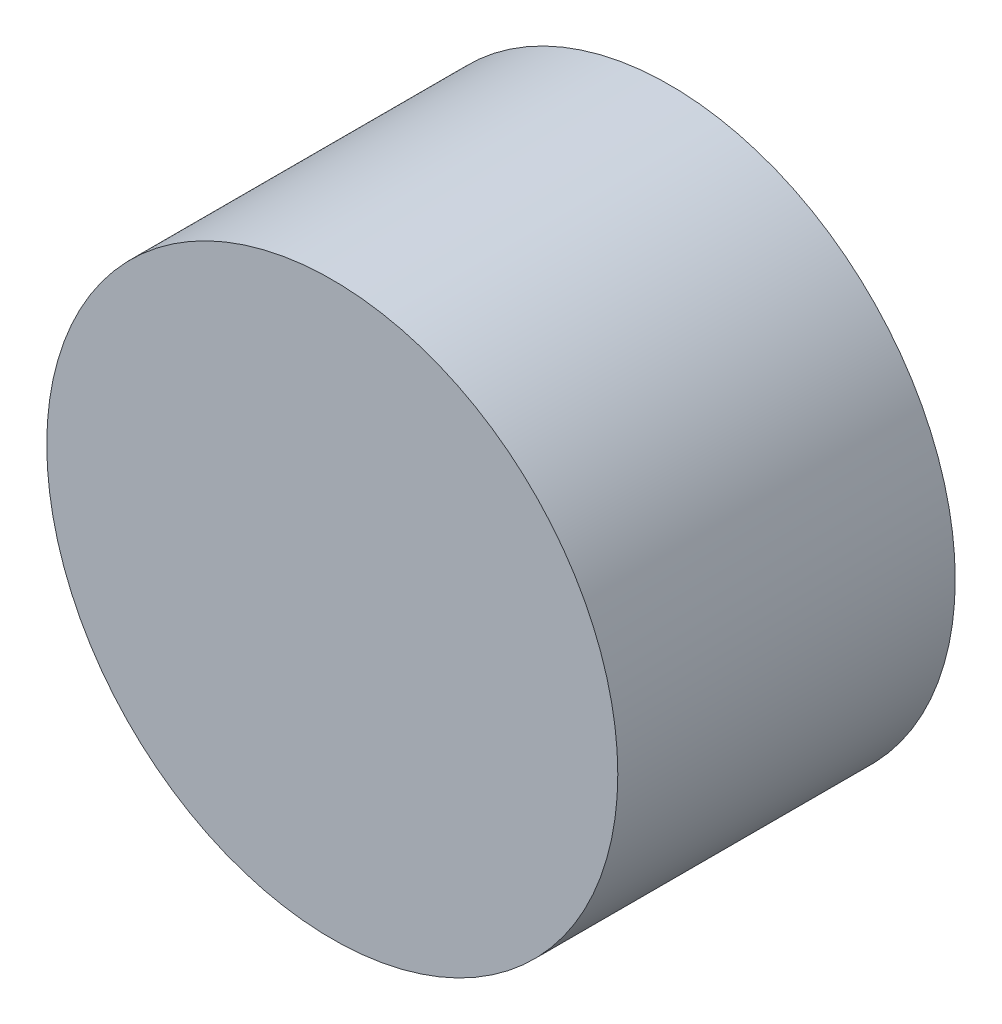
from build123d import *

# Parameters (mm, degrees)
SKETCH1_R           = 2.75
BOSS_EXTRUDE1_DEPTH = 3.25


with BuildPart() as part:
    # Sketch1 → Boss-Extrude1 (new body)
    with BuildSketch(Plane.XY):
        Circle(SKETCH1_R)
    extrude(amount=BOSS_EXTRUDE1_DEPTH)


solid = part.part
